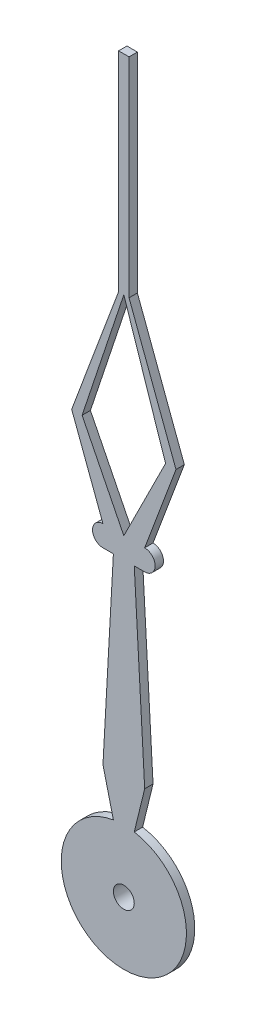
from build123d import *

# Parameters (mm, degrees)
CROQUIS1_R              = 0.25
SALIENTE_EXTRUIR1_DEPTH = 0.2
CROQUIS2_R              = 0.5
CROQUIS2_R_2            = 0.25
SALIENTE_EXTRUIR2_DEPTH = 0.2


with BuildPart() as part:
    # Croquis1 → Saliente-Extruir1 (new body)
    with BuildSketch(Plane.XY):
        with BuildLine():
            Line((-0.5, 7), (-0.25, 7))
            Line((-0.25, 7), (-0.5, 2.5))
            Line((-0.5, 2.5), (-0.25, 1.479019946))
            ThreePointArc((-0.25, 1.479019946), (0, -1.5), (0.25, 1.479019946))
            Line((0.25, 1.479019946), (0.5, 2.5))
            Line((0.5, 2.5), (0.25, 7))
            Line((0.25, 7), (0.5, 7))
            ThreePointArc((0.5, 7), (0.75, 7.25), (0.5, 7.5))
            Line((0.5, 7.5), (1.25, 9.5))
            Line((1.25, 9.5), (0.125, 12.5))
            Line((0.125, 12.5), (0.125, 17.5))
            Line((0.125, 17.5), (-0.125, 17.5))
            Line((-0.125, 17.5), (-0.125, 12.5))
            Line((-0.125, 12.5), (-1.25, 9.5))
            Line((-1.25, 9.5), (-0.5, 7.5))
            ThreePointArc((-0.5, 7.5), (-0.75, 7.25), (-0.5, 7))
        make_face()
        Circle(CROQUIS1_R, mode=Mode.SUBTRACT)
        Polygon((0, 7.5), (-1, 9.5), (0, 12.5), (1, 9.5), align=None, mode=Mode.SUBTRACT)
    extrude(amount=SALIENTE_EXTRUIR1_DEPTH)

    # Croquis2 → Saliente-Extruir2 (add)
    with BuildSketch(Plane(origin=(0, 0, 0), x_dir=(-1, 0, 0), z_dir=(0, 0, -1))):
        Circle(CROQUIS2_R)
        Circle(CROQUIS2_R_2, mode=Mode.SUBTRACT)
    extrude(amount=SALIENTE_EXTRUIR2_DEPTH)


solid = part.part
